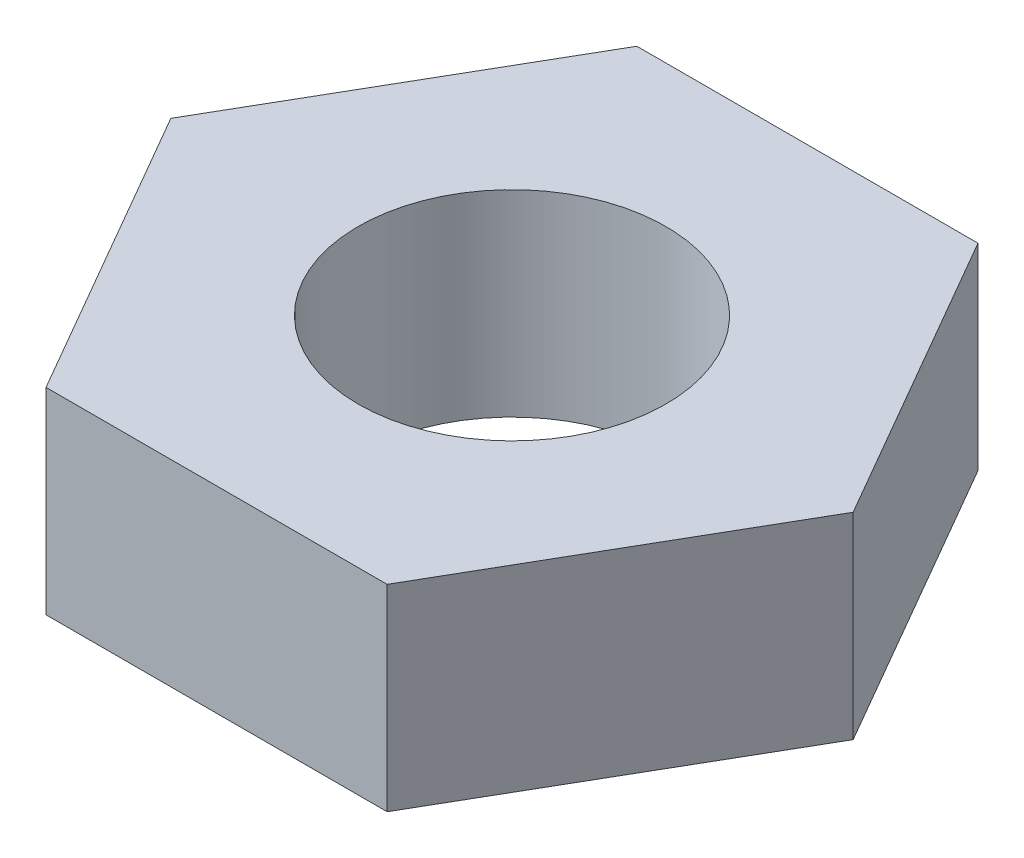
from build123d import *

# Parameters (mm, degrees)
BOSS_EXTRUDE1_DEPTH      = 6.35
F_7_16_20_TAPPED_HOLE1_D = 9.92124


with BuildPart() as part:
    # Sketch1 → Boss-Extrude1 (new body)
    with BuildSketch(Plane(origin=(0, 0, 0), x_dir=(1, 0, 0), z_dir=(0, 1, 0))):
        Polygon((5.499261314, 9.525), (-5.499261314, 9.525), (-10.998522628, 0), (-5.499261314, -9.525), (5.499261314, -9.525), (10.998522628, 0), align=None)
    extrude(amount=BOSS_EXTRUDE1_DEPTH)

    # 7/16-20 Tapped Hole1 (through all)
    with Locations(Plane(origin=(0, 6.35, 0), x_dir=(1, 0, 0), z_dir=(0, 1, 0))):
        with Locations((0, 0)):
            Hole(F_7_16_20_TAPPED_HOLE1_D / 2)


solid = part.part
